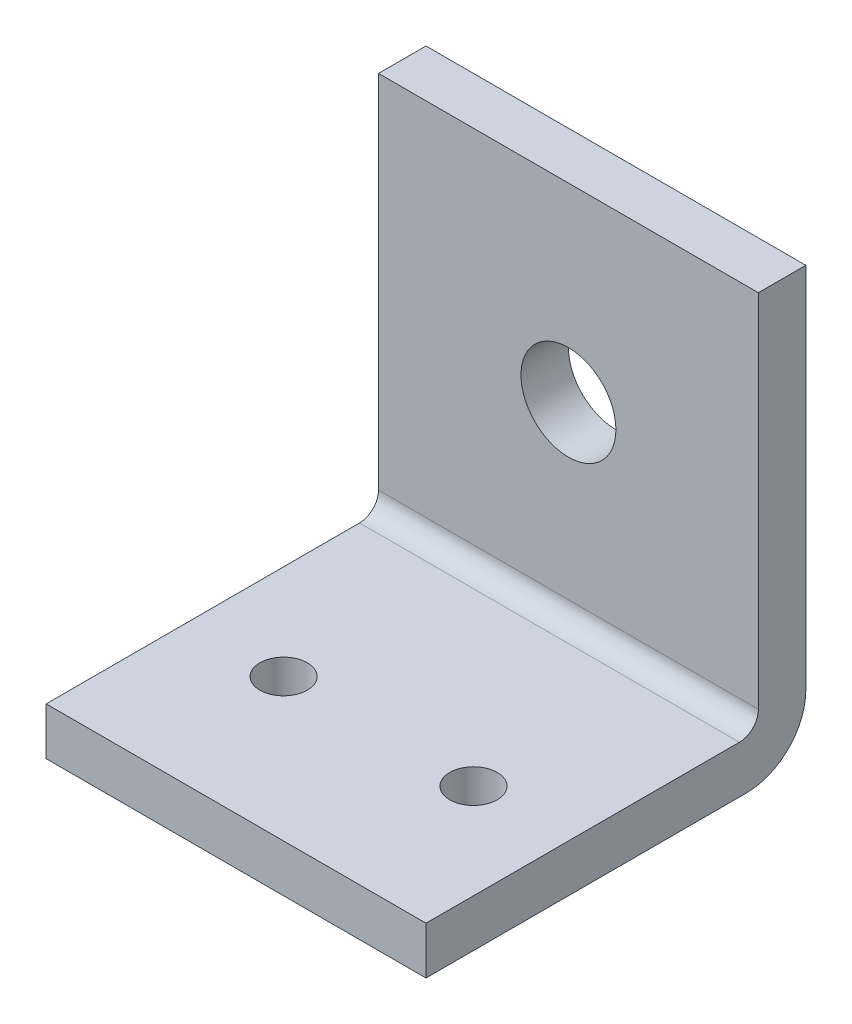
from build123d import *

# Parameters (mm, degrees)
SKETCH2_W           = 40
SKETCH2_H           = 5
BOSS_EXTRUDE1_DEPTH = 40
SKETCH3_W           = 40
SKETCH3_H           = 5
BOSS_EXTRUDE2_DEPTH = 40
SKETCH4_R           = 2.5
CUT_EXTRUDE1_DEPTH  = 10
SKETCH5_R           = 5
CUT_EXTRUDE2_DEPTH  = 10
FILLET1_R           = 6.25
FILLET2_R           = 2


with BuildPart() as part:
    # Sketch2 → Boss-Extrude1 (new body)
    with BuildSketch(Plane.XY):
        with Locations((20, 2.5)):
            Rectangle(SKETCH2_W, SKETCH2_H)
    extrude(amount=BOSS_EXTRUDE1_DEPTH)

    # Sketch3 → Boss-Extrude2 (add)
    with BuildSketch(Plane(origin=(0, 5, 0), x_dir=(1, 0, 0), z_dir=(0, 1, 0))):
        with Locations((20, -2.5)):
            Rectangle(SKETCH3_W, SKETCH3_H)
    extrude(amount=BOSS_EXTRUDE2_DEPTH)

    # Sketch4 → Cut-Extrude1 (cut)
    with BuildSketch(Plane(origin=(0, 5, 0), x_dir=(1, 0, 0), z_dir=(0, 1, 0))):
        with Locations((10, -25)):
            Circle(SKETCH4_R)
        with Locations((30, -25)):
            Circle(SKETCH4_R)
    extrude(amount=-CUT_EXTRUDE1_DEPTH, mode=Mode.SUBTRACT)

    # Sketch5 → Cut-Extrude2 (cut)
    with BuildSketch(Plane.XY.offset(5)):
        with Locations((20, 25)):
            Circle(SKETCH5_R)
    extrude(amount=-CUT_EXTRUDE2_DEPTH, mode=Mode.SUBTRACT)

    # Fillet1
    fillet1_edges = [part.edges().sort_by_distance(p)[0] for p in [
        (20, 0, 0),
    ]]
    fillet(fillet1_edges, radius=FILLET1_R)

    # Fillet2
    fillet2_edges = [part.edges().sort_by_distance(p)[0] for p in [
        (20, 5, 5),
    ]]
    fillet(fillet2_edges, radius=FILLET2_R)


solid = part.part
